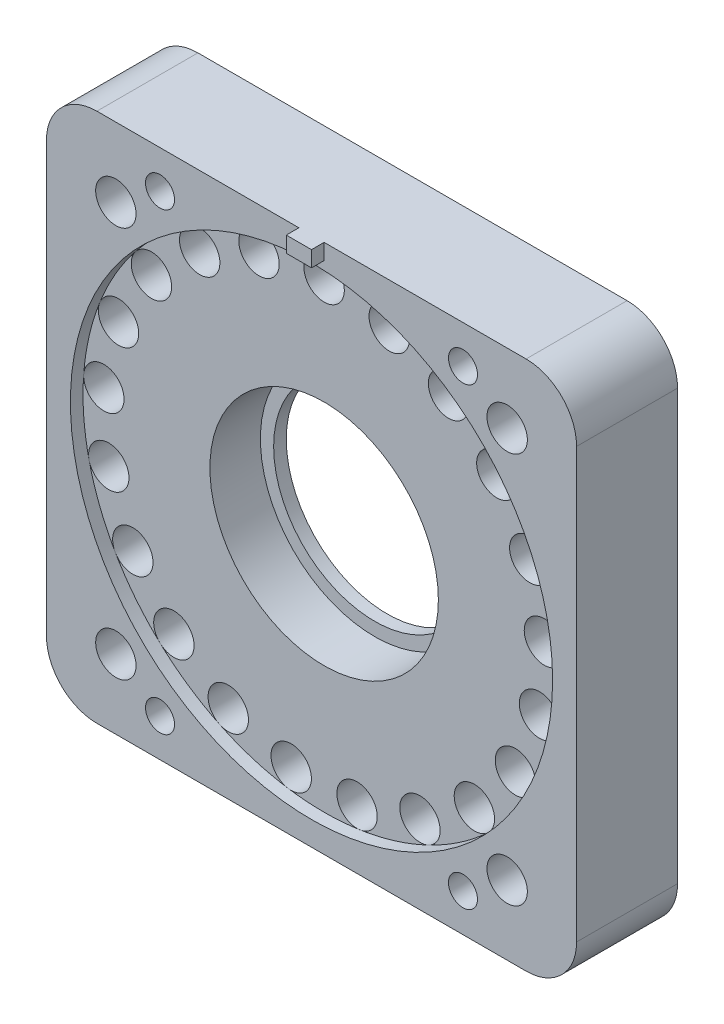
from build123d import *

# Parameters (mm, degrees)
SKETCH_1_W               = 42
SKETCH_1_H               = 42
EXTRUDE_1_DEPTH          = 8
SKETCH_2_R               = 19.1
CUT_EXTRUDE_1_DEPTH      = 1
SKETCH_3_R               = 1.6
CUT_EXTRUDE_2_DEPTH      = 2.5
PATTERN_CIRCULAR_1_COUNT = 21
SKETCH_4_R               = 9.05
CUT_EXTRUDE_3_DEPTH      = 4
SKETCH_5_R               = 11.05
CUT_EXTRUDE_4_DEPTH      = 2
SKETCH_6_R               = 8
CUT_EXTRUDE_5_DEPTH      = 7
FILLET_1_R               = 4
SKETCH_8_R               = 1.15
SKETCH_8_R_2             = 1.6
CUT_EXTRUDE_6_DEPTH      = 9
SKETCH_9_R               = 1.65
CUT_EXTRUDE_7_DEPTH      = 6
SKETCH_10_W              = 2
SKETCH_10_H              = 1.25
EXTRUDE_2_DEPTH          = 1


with BuildPart() as part:
    # 草图1 → 凸台-拉伸1 (new body)
    with BuildSketch(Plane.XY):
        Rectangle(SKETCH_1_W, SKETCH_1_H)
    extrude(amount=EXTRUDE_1_DEPTH)

    # 草图2 → 切除-拉伸1 (cut)
    with BuildSketch(Plane.XY.offset(8)):
        Circle(SKETCH_2_R)
    extrude(amount=-CUT_EXTRUDE_1_DEPTH, mode=Mode.SUBTRACT)

    # 草图3 → 切除-拉伸2 (cut)
    with BuildSketch(Plane.XY.offset(7)):
        with Locations((0, 17.5)):
            Circle(SKETCH_3_R)
    cut_extrude_2 = extrude(amount=-CUT_EXTRUDE_2_DEPTH, mode=Mode.SUBTRACT)

    # 阵列(圆周)1: 切除-拉伸2 ×21 about axis
    pattern_circular_1_axis = Axis((0, 0, 0), (0, 0, 1))
    for i in range(1, PATTERN_CIRCULAR_1_COUNT):
        add(cut_extrude_2.rotate(pattern_circular_1_axis, i * 360 / PATTERN_CIRCULAR_1_COUNT), mode=Mode.SUBTRACT)

    # 草图4 → 切除-拉伸3 (cut)
    with BuildSketch(Plane.XY.offset(7)):
        Circle(SKETCH_4_R)
    extrude(amount=-CUT_EXTRUDE_3_DEPTH, mode=Mode.SUBTRACT)

    # 草图5 → 切除-拉伸4 (cut)
    with BuildSketch(Plane(origin=(0, 0, 0), x_dir=(-1, 0, 0), z_dir=(0, 0, -1))):
        Circle(SKETCH_5_R)
    extrude(amount=-CUT_EXTRUDE_4_DEPTH, mode=Mode.SUBTRACT)

    # 草图6 → 切除-拉伸5 (cut, through all)
    with BuildSketch(Plane(origin=(0, 0, 2), x_dir=(-1, 0, 0), z_dir=(0, 0, -1))):
        Circle(SKETCH_6_R)
    extrude(amount=-CUT_EXTRUDE_5_DEPTH, mode=Mode.SUBTRACT)

    # 圆角1
    fillet_1_edges = [part.edges().sort_by_distance(p)[0] for p in [
        (21, -21, 4),
        (-21, -21, 4),
        (-21, 21, 4),
        (21, 21, 4),
    ]]
    fillet(fillet_1_edges, radius=FILLET_1_R)

    # 草图8 → 切除-拉伸6 (cut, through all)
    with BuildSketch(Plane.XY.offset(8)):
        with Locations((-12, 18)):
            Circle(SKETCH_8_R)
        with Locations((-15.5, 15.5)):
            Circle(SKETCH_8_R_2)
        with Locations((15.5, 15.5)):
            Circle(SKETCH_8_R_2)
        with Locations((12, 18)):
            Circle(SKETCH_8_R)
        with Locations((15.5, -15.5)):
            Circle(SKETCH_8_R_2)
        with Locations((12, -18)):
            Circle(SKETCH_8_R)
        with Locations((-12, -18)):
            Circle(SKETCH_8_R)
        with Locations((-15.5, -15.5)):
            Circle(SKETCH_8_R_2)
    extrude(amount=-CUT_EXTRUDE_6_DEPTH, mode=Mode.SUBTRACT)

    # 草图9 → 切除-拉伸7 (cut)
    with BuildSketch(Plane(origin=(0, 0, 0), x_dir=(-1, 0, 0), z_dir=(0, 0, -1))):
        with Locations((-12, 18)):
            Circle(SKETCH_9_R)
        with Locations((12, 18)):
            Circle(SKETCH_9_R)
        with Locations((-12, -18)):
            Circle(SKETCH_9_R)
        with Locations((12, -18)):
            Circle(SKETCH_9_R)
    extrude(amount=-CUT_EXTRUDE_7_DEPTH, mode=Mode.SUBTRACT)

    # 草图10 → 凸台-拉伸2 (add)
    with BuildSketch(Plane.XY.offset(8)):
        with Locations((0, 20.375)):
            Rectangle(SKETCH_10_W, SKETCH_10_H)
    extrude(amount=EXTRUDE_2_DEPTH)


solid = part.part
